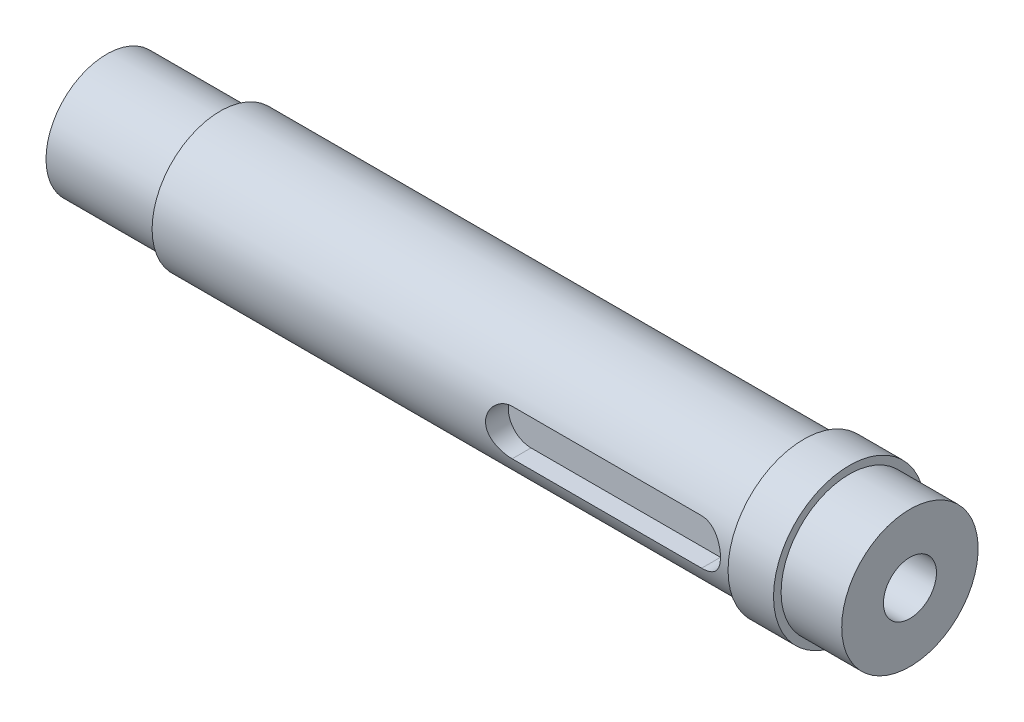
from build123d import *

# Parameters (mm, degrees)
CUT_EXTRUDE_2_DEPTH = 3
SKETCH_5_R          = 3.5
CUT_EXTRUDE_3_DEPTH = 107


with BuildPart() as part:
    # 草图2 → 旋转1 (revolve)
    with BuildSketch(Plane(origin=(0, 0, 0), x_dir=(1, 0, 0), z_dir=(0, 1, 0))):
        Polygon((0, 0), (0, 8), (15, 8), (15, 9), (92, 9), (92, 10), (98, 10), (98, 9), (106, 9), (106, 0), align=None)
    revolve(axis=Axis((0, 0, 0), (1, 0, 0)))

    # 草图4 → 切除-拉伸2 (cut)
    with BuildSketch(Plane.XY.offset(9)):
        with BuildLine():
            Line((62, 3), (87, 3))
            ThreePointArc((87, 3), (90, 0), (87, -3))
            Line((87, -3), (62, -3))
            ThreePointArc((62, -3), (59, 0), (62, 3))
        make_face()
    extrude(amount=-CUT_EXTRUDE_2_DEPTH, mode=Mode.SUBTRACT)

    # 草图5 → 切除-拉伸3 (cut, through all)
    with BuildSketch(Plane(origin=(106, 0, 0), x_dir=(0, 0, -1), z_dir=(1, 0, 0))):
        Circle(SKETCH_5_R)
    extrude(amount=-CUT_EXTRUDE_3_DEPTH, mode=Mode.SUBTRACT)


solid = part.part
